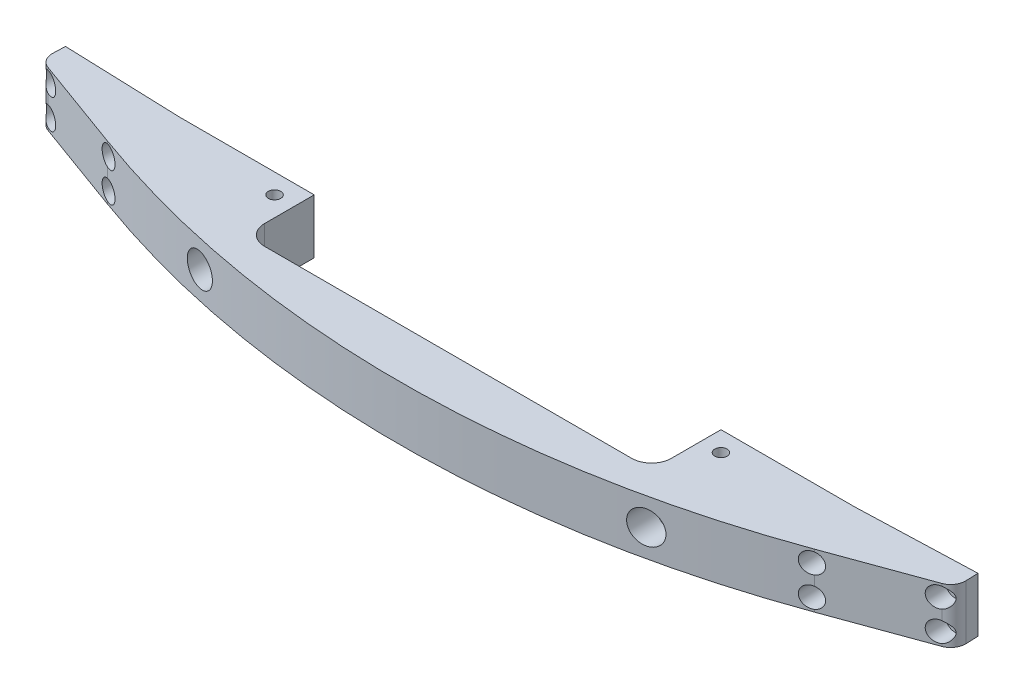
from build123d import *

# Parameters (mm, degrees)
AUFSATZ_LINEAR_AUSTRAGEN1_DEPTH                      = 5.5
VERRUNDUNG1_R                                        = 4
M3_GEWINDEBOHRUNG1_D                                 = 2.5
VERRUNDUNG2_R                                        = 3
SCHNITT_LINEAR_START                                 = -2
SKIZZE7_R                                            = 2.05
SCHNITT_LINEAR_AUSTRAGEN1_DEPTH                      = 93.78726116
SKIZZE7_3_R                                          = 1
SCHNITT_LINEAR_AUSTRAGEN2_DEPTH                      = 95.787261285
STIRNSENKUNG_F_R_M3_ZYLINDERSCHRAUBE_MIT_D           = 3.2
STIRNSENKUNG_F_R_M3_ZYLINDERSCHRAUBE_MIT_CBORE_D     = 6.5
STIRNSENKUNG_F_R_M3_ZYLINDERSCHRAUBE_MIT_CBORE_DEPTH = 10


with BuildPart() as part:
    # Skizze1 → Aufsatz-Linear austragen1 (new, symmetric)
    with BuildSketch(Plane(origin=(0, 0, 0), x_dir=(1, 0, 0), z_dir=(0, 1, 0))):
        with BuildLine():
            Line((-91.978065317, 4.837587921), (-92.141327499, 0.162370724))
            Line((-92.141327499, 0.162370724), (-71.275303416, -7.43224095))
            ThreePointArc((-71.275303416, -7.43224095), (-36.187419929, -16.834010994), (0, -20))
            Line((0, -20), (0, -10))
            Line((0, -10), (-41, -10))
            Line((-41, -10), (-41, 4))
            Line((-41, 4), (-67.992685468, 4))
            Line((-67.992685468, 4), (-91.978065317, 4.837587921))
        make_face()
    extrude(amount=AUFSATZ_LINEAR_AUSTRAGEN1_DEPTH, both=True)

    # Verrundung1
    verrundung1_edges = [part.edges().sort_by_distance(p)[0] for p in [
        (-41, 0, 10),
    ]]
    fillet(verrundung1_edges, radius=VERRUNDUNG1_R)

    # M3 Gewindebohrung1 (through all)
    with Locations(Plane(origin=(-37.688737351, 5.5, 8.480848773), x_dir=(1, 0, 0), z_dir=(0, 1, 0))):
        with Locations((-7.311262649, 8.480848773)):
            Hole(M3_GEWINDEBOHRUNG1_D / 2)

    # Verrundung2
    verrundung2_edges = [part.edges().sort_by_distance(p)[0] for p in [
        (-92.141327499, 0, -0.162370724),
    ]]
    fillet(verrundung2_edges, radius=VERRUNDUNG2_R)

    # Skizze7 → Schnitt-Linear austragen1 (cut, through all)
    with BuildSketch(Plane(origin=(0.056699565, 0, -1.623663111), x_dir=(-0.9993908270190958, 0, -0.03489949670250085), z_dir=(0.03489949670250085, 0, -0.9993908270190958)).offset(SCHNITT_LINEAR_START)):
        with Locations((70.590864148, 3)):
            Circle(SKIZZE7_R)
        with Locations((89.590864148, 3)):
            Circle(SKIZZE7_R)
        with Locations((89.590864148, -3)):
            Circle(SKIZZE7_R)
        with Locations((70.590864148, -3)):
            Circle(SKIZZE7_R)
    extrude(amount=-SCHNITT_LINEAR_AUSTRAGEN1_DEPTH, mode=Mode.SUBTRACT)

    # Skizze7_3 → Schnitt-Linear austragen2 (cut, through all)
    with BuildSketch(Plane(origin=(0.056699565, 0, -1.623663111), x_dir=(-0.9993908270190958, 0, -0.03489949670250085), z_dir=(0.03489949670250085, 0, -0.9993908270190958))):
        with Locations((70.590864148, -3)):
            Circle(SKIZZE7_3_R)
        with Locations((89.590864148, -3)):
            Circle(SKIZZE7_3_R)
        with Locations((89.590864148, 3)):
            Circle(SKIZZE7_3_R)
        with Locations((70.590864148, 3)):
            Circle(SKIZZE7_3_R)
    extrude(amount=-SCHNITT_LINEAR_AUSTRAGEN2_DEPTH, mode=Mode.SUBTRACT)

    # Spiegeln3: part across plane


with BuildPart() as part_1:
    add(part.part)
    add(part.part.mirror(Plane(origin=(0, 0, 0), x_dir=(0, 0, 1), z_dir=(1, 0, 0))))

    # Stirnsenkung für  M3 Zylinderschraube mit Schlitz/Kreuzschlitz1 (through all)
    with Locations(Plane.XY.offset(20)):
        with Locations((-45, 0), (45, 0)):
            CounterBoreHole(STIRNSENKUNG_F_R_M3_ZYLINDERSCHRAUBE_MIT_D / 2, STIRNSENKUNG_F_R_M3_ZYLINDERSCHRAUBE_MIT_CBORE_D / 2, STIRNSENKUNG_F_R_M3_ZYLINDERSCHRAUBE_MIT_CBORE_DEPTH)


solid = part_1.part
